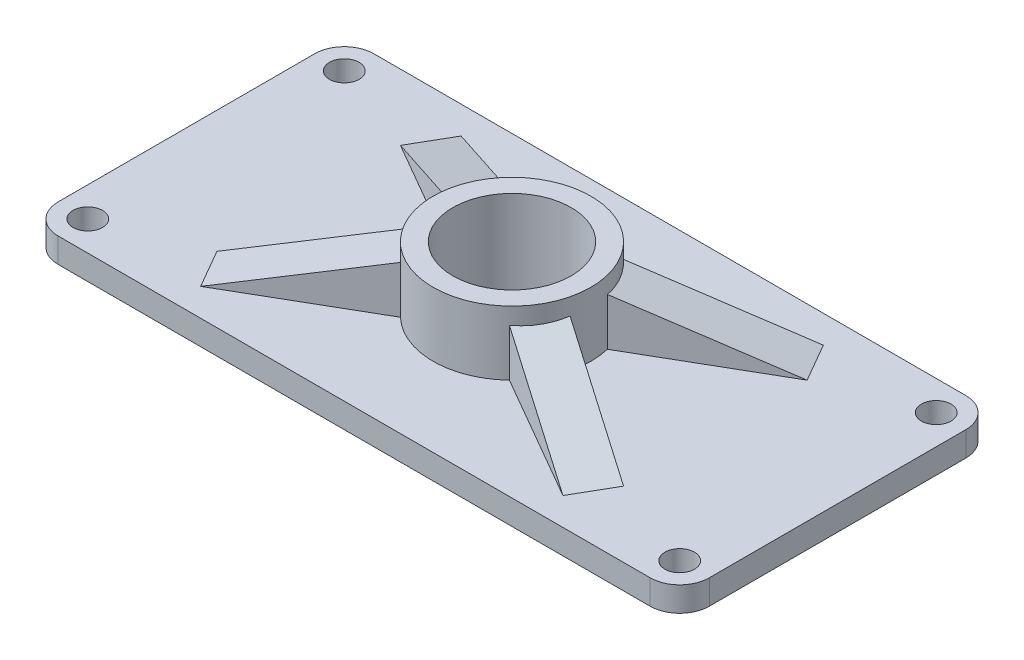
from build123d import *

# Parameters (mm, degrees)
SKETCH1_R           = 3
BOSS_EXTRUDE1_DEPTH = 5
SKETCH2_R           = 12
CUT_EXTRUDE1_DEPTH  = 5
BOSS_EXTRUDE2_START = 13
SKETCH2_3_R         = 16
SKETCH2_3_R_2       = 12
BOSS_EXTRUDE2_DEPTH = 13
BOSS_EXTRUDE5_DEPTH = 4.5


with BuildPart() as part:
    # Sketch1 → Boss-Extrude1 (new body)
    with BuildSketch(Plane(origin=(0, 0, 0), x_dir=(1, 0, 0), z_dir=(0, 1, 0))):
        with BuildLine():
            Line((-60, 32), (60, 32))
            ThreePointArc((60, 32), (64.242640687, 30.242640687), (66, 26))
            Line((66, 26), (66, -26))
            ThreePointArc((66, -26), (64.242640687, -30.242640687), (60, -32))
            Line((60, -32), (-60, -32))
            ThreePointArc((-60, -32), (-64.242640687, -30.242640687), (-66, -26))
            Line((-66, -26), (-66, 26))
            ThreePointArc((-66, 26), (-64.242640687, 30.242640687), (-60, 32))
        make_face()
        with Locations((-60, 26)):
            Circle(SKETCH1_R, mode=Mode.SUBTRACT)
        with Locations((-60, -26)):
            Circle(SKETCH1_R, mode=Mode.SUBTRACT)
        with Locations((60, 26)):
            Circle(SKETCH1_R, mode=Mode.SUBTRACT)
        with Locations((60, -26)):
            Circle(SKETCH1_R, mode=Mode.SUBTRACT)
    extrude(amount=BOSS_EXTRUDE1_DEPTH)

    # Sketch2 → Cut-Extrude1 (cut)
    with BuildSketch(Plane(origin=(0, 5, 0), x_dir=(1, 0, 0), z_dir=(0, 1, 0))):
        Circle(SKETCH2_R)
    extrude(amount=-CUT_EXTRUDE1_DEPTH, mode=Mode.SUBTRACT)

    # Sketch2_3 → Boss-Extrude2 (add)
    with BuildSketch(Plane(origin=(0, 5, 0), x_dir=(1, 0, 0), z_dir=(0, 1, 0)).offset(BOSS_EXTRUDE2_START)):
        Circle(SKETCH2_3_R)
        Circle(SKETCH2_3_R_2, mode=Mode.SUBTRACT)
    extrude(amount=-BOSS_EXTRUDE2_DEPTH)

    # Sketch4 → Boss-Extrude5 (add, symmetric)
    with BuildSketch(Plane(origin=(0, 0, 0), x_dir=(0.8660254037844379, 0, -0.5000000000000014), z_dir=(0.5000000000000014, 0, 0.8660254037844379))):
        Polygon((-45, 5), (-14.70481954, 14.843500832), (-14.70481954, 5), align=None)
        Polygon((14.70481954, 14.843500832), (14.70481954, 5), (45, 5), align=None)
    boss_extrude5 = extrude(amount=BOSS_EXTRUDE5_DEPTH, both=True)

    # Mirror1: Boss-Extrude5 across plane
    add(boss_extrude5.mirror(Plane.XY))


solid = part.part
